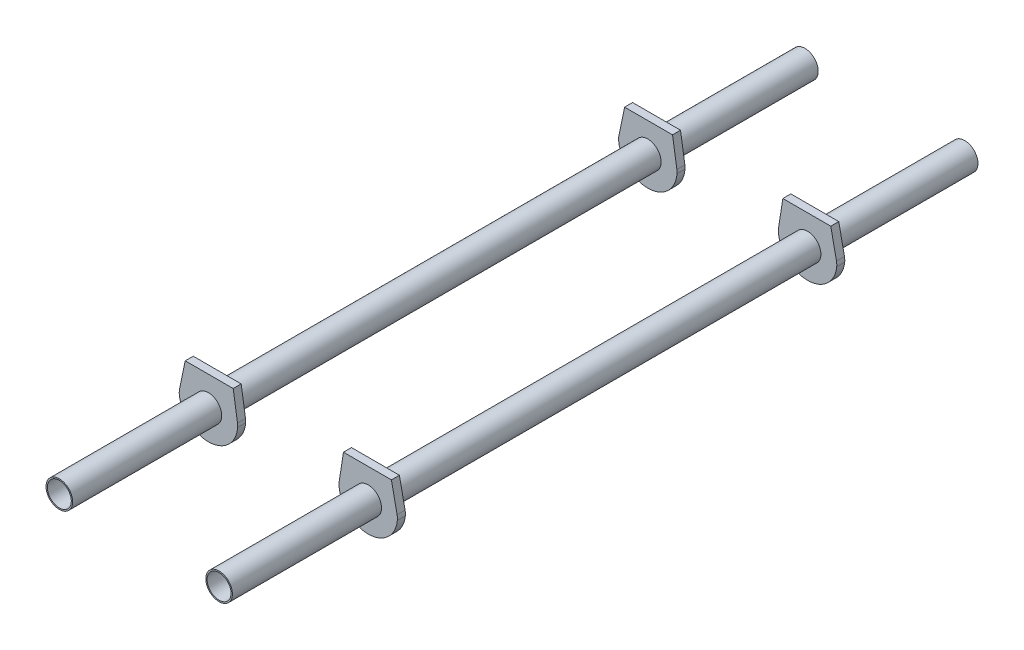
from build123d import *

# Parameters (mm, degrees)
SCHIZZO1_R                   = 5
SCHIZZO1_R_2                 = 4.5
ESTRUSIONE_ESTRUSIONE1_DEPTH = 140
ESTRUSIONE_ESTRUSIONE2_START = 82.5
SCHIZZO2_R                   = 5
ESTRUSIONE_ESTRUSIONE2_DEPTH = 1.5


with BuildPart() as part:
    # Schizzo1 → Estrusione-Estrusione1 (new body, symmetric)
    with BuildSketch(Plane.XY):
        with Locations((30, 0)):
            Circle(SCHIZZO1_R)
        with Locations((30, 0)):
            Circle(SCHIZZO1_R_2, mode=Mode.SUBTRACT)
    extrude(amount=ESTRUSIONE_ESTRUSIONE1_DEPTH, both=True)

    # Schizzo2 → Estrusione-Estrusione2 (add, symmetric)
    with BuildSketch(Plane.XY.offset(ESTRUSIONE_ESTRUSIONE2_START)):
        with BuildLine():
            Line((19.085389697, 0.548640093), (20.712027021, 11))
            Line((20.712027021, 11), (38.712027021, 11))
            Line((38.712027021, 11), (40.849423677, 0.72393318))
            ThreePointArc((40.849423677, 0.72393318), (40.966829068, -0.18206425), (40.945324752, -1.095383983))
            ThreePointArc((40.945324752, -1.095383983), (29.863279468, -10.999150308), (19.030829735, -0.822984631))
            ThreePointArc((19.030829735, -0.822984631), (19.018754667, -0.135606819), (19.085389697, 0.548640093))
        make_face()
        with Locations((30, 0)):
            Circle(SCHIZZO2_R, mode=Mode.SUBTRACT)
    extrude(amount=ESTRUSIONE_ESTRUSIONE2_DEPTH, both=True)

    # Specchia5: part across plane


with BuildPart() as part_1:
    add(part.part)
    add(part.part.mirror(Plane.XY))


with BuildPart() as body_2:
    # Specchia9: mirrored copy
    add(part_1.part.mirror(Plane(origin=(0, 0, 0), x_dir=(0, 0, 1), z_dir=(1, 0, 0))))


solid = Compound([part_1.part, body_2.part])
